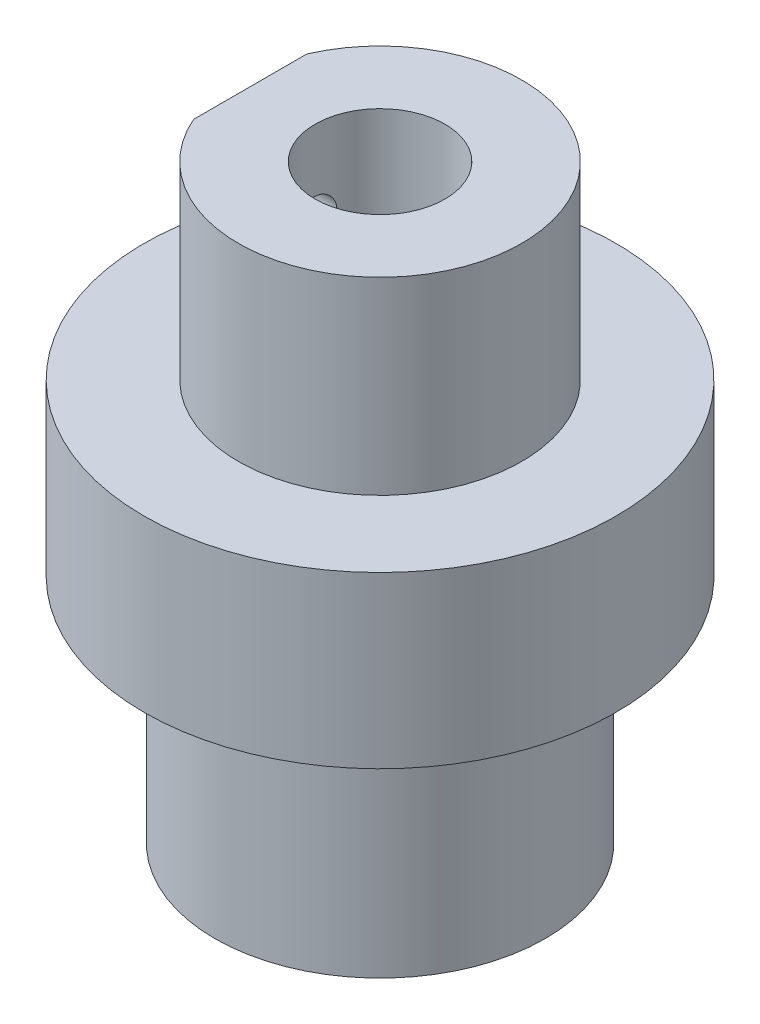
from build123d import *

# Parameters (mm, degrees)
SKETCH5_R             = 7
BOSS_EXTRUDE2_DEPTH   = 9.8
SKETCH6_R             = 10
BOSS_EXTRUDE3_DEPTH   = 7.2
M8_TAPPED_HOLE2_D     = 6.8
M8_TAPPED_HOLE2_DEPTH = 17
M8_TAPPED_HOLE2_TIP   = 2.042926105
BOSS_EXTRUDE5_DEPTH   = 8
SKETCH12_R            = 2.75
CUT_EXTRUDE6_DEPTH    = 9
M2_TAPPED_HOLE1_D     = 1.6
M2_TAPPED_HOLE1_DEPTH = 5.2
M2_TAPPED_HOLE1_TIP   = 0.480688495


with BuildPart() as part:
    # Sketch5 → Boss-Extrude2 (new body)
    with BuildSketch(Plane(origin=(0, 0, 0), x_dir=(1, 0, 0), z_dir=(0, 1, 0))):
        Circle(SKETCH5_R)
    extrude(amount=BOSS_EXTRUDE2_DEPTH)

    # Sketch6 → Boss-Extrude3 (add)
    with BuildSketch(Plane(origin=(0, 9.8, 0), x_dir=(1, 0, 0), z_dir=(0, 1, 0))):
        Circle(SKETCH6_R)
    extrude(amount=BOSS_EXTRUDE3_DEPTH)

    # M8 Tapped Hole2
    with Locations(Plane(origin=(0, 0, 0), x_dir=(-1, 0, 0), z_dir=(0, -1, 0))):
        with Locations((0, 0)):
            Hole(M8_TAPPED_HOLE2_D / 2, depth=M8_TAPPED_HOLE2_DEPTH)
            with Locations((0, 0, -(M8_TAPPED_HOLE2_DEPTH + M8_TAPPED_HOLE2_TIP / 2))):  # 118° drill point
                Cone(0, M8_TAPPED_HOLE2_D / 2, M8_TAPPED_HOLE2_TIP, mode=Mode.SUBTRACT)

    # Sketch11 → Boss-Extrude5 (add)
    with BuildSketch(Plane(origin=(0, 17, 0), x_dir=(1, 0, 0), z_dir=(0, 1, 0))):
        with BuildLine():
            Line((-5.5, 2.397915762), (-5.5, -2.397915762))
            ThreePointArc((-5.5, -2.397915762), (6, 0), (-5.5, 2.397915762))
        make_face()
    extrude(amount=BOSS_EXTRUDE5_DEPTH)

    # Sketch12 → Cut-Extrude6 (cut)
    with BuildSketch(Plane(origin=(0, 25, 0), x_dir=(1, 0, 0), z_dir=(0, 1, 0))):
        Circle(SKETCH12_R)
    extrude(amount=-CUT_EXTRUDE6_DEPTH, mode=Mode.SUBTRACT)

    # M2 Tapped Hole1
    with Locations(Plane.ZY.offset(5.5)):
        with Locations((0, 21.552134156)):
            Hole(M2_TAPPED_HOLE1_D / 2, depth=M2_TAPPED_HOLE1_DEPTH)
            with Locations((0, 0, -(M2_TAPPED_HOLE1_DEPTH + M2_TAPPED_HOLE1_TIP / 2))):  # 118° drill point
                Cone(0, M2_TAPPED_HOLE1_D / 2, M2_TAPPED_HOLE1_TIP, mode=Mode.SUBTRACT)


solid = part.part
